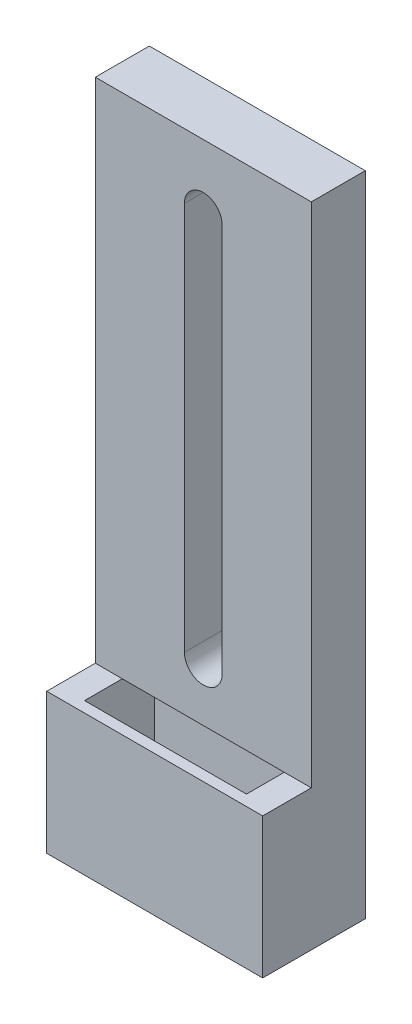
from build123d import *

# Parameters (mm, degrees)
SKETCH1_W           = 20
SKETCH1_H           = 60
BOSS_EXTRUDE1_DEPTH = 5
SKETCH2_W           = 20
SKETCH2_H           = 13
BOSS_EXTRUDE2_DEPTH = 4.5
SKETCH3_W           = 15
SKETCH3_H           = 6.5
CUT_EXTRUDE1_DEPTH  = 14
CUT_EXTRUDE2_DEPTH  = 10


with BuildPart() as part:
    # Sketch1 → Boss-Extrude1 (new body)
    with BuildSketch(Plane.XY):
        with Locations((10, 30)):
            Rectangle(SKETCH1_W, SKETCH1_H)
    extrude(amount=BOSS_EXTRUDE1_DEPTH)

    # Sketch2 → Boss-Extrude2 (add)
    with BuildSketch(Plane.XY.offset(5)):
        with Locations((10, 6.5)):
            Rectangle(SKETCH2_W, SKETCH2_H)
    extrude(amount=BOSS_EXTRUDE2_DEPTH)

    # Sketch3 → Cut-Extrude1 (cut, through all)
    with BuildSketch(Plane(origin=(0, 13, 0), x_dir=(1, 0, 0), z_dir=(0, 1, 0))):
        with Locations((10, -5.25)):
            Rectangle(SKETCH3_W, SKETCH3_H)
    extrude(amount=-CUT_EXTRUDE1_DEPTH, mode=Mode.SUBTRACT)

    # Sketch4 → Cut-Extrude2 (cut)
    with BuildSketch(Plane.XY.offset(5)):
        with BuildLine():
            Line((11.75, 54), (11.75, 18))
            ThreePointArc((11.75, 18), (10, 16.25), (8.25, 18))
            Line((8.25, 18), (8.25, 54))
            ThreePointArc((8.25, 54), (10, 55.75), (11.75, 54))
        make_face()
    extrude(amount=-CUT_EXTRUDE2_DEPTH, mode=Mode.SUBTRACT)


solid = part.part
